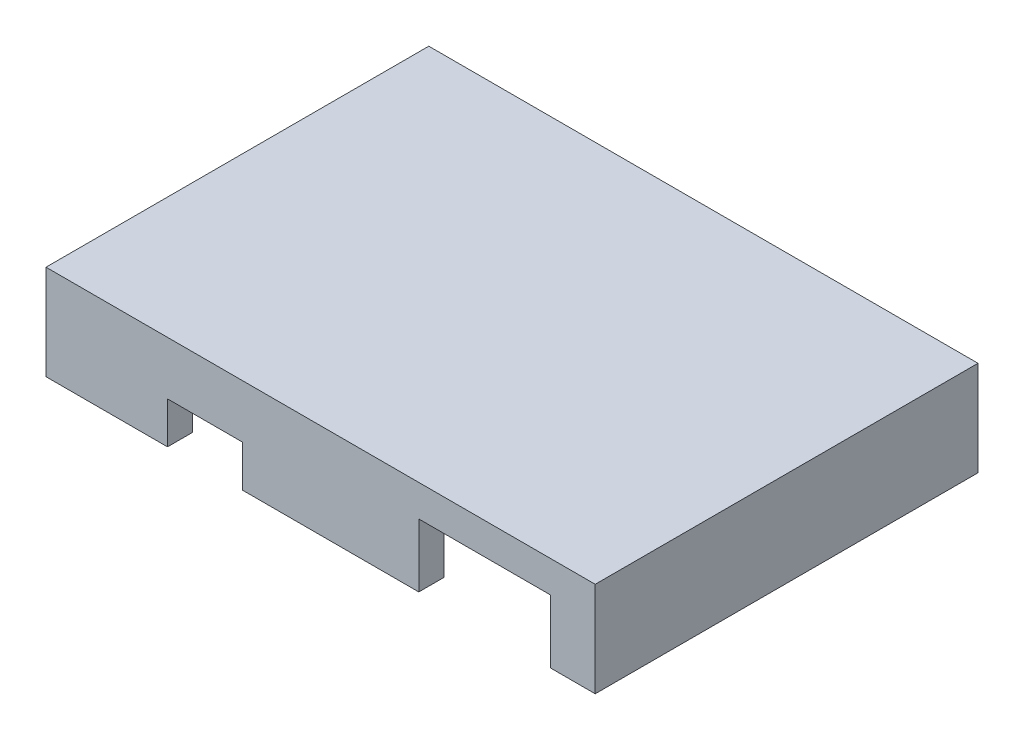
from build123d import *

# Parameters (mm, degrees)
SKETCH1_W           = 33
SKETCH1_H           = 23
SKETCH1_W_2         = 30
SKETCH1_H_2         = 20
BOSS_EXTRUDE1_DEPTH = 5.7
SKETCH2_W           = 30
SKETCH2_H           = 20
BOSS_EXTRUDE2_DEPTH = 1.5
CUT_EXTRUDE1_REACH  = 25
SKETCH3_W           = 7.5
SKETCH3_H           = 3.6
CUT_EXTRUDE2_REACH  = 25
SKETCH4_W           = 7.9
SKETCH4_H           = 7.6
SKETCH4_W_2         = 4.5
SKETCH4_H_2         = 5
CUT_EXTRUDE3_REACH  = 35
SKETCH5_W           = 3.35
SKETCH5_H           = 5
SKETCH6_W           = 2
SKETCH6_H           = 12.5
BOSS_EXTRUDE3_DEPTH = 2.2
SKETCH7_W           = 1.2
SKETCH7_H           = 3.3
SKETCH7_H_2         = 1.2
BOSS_EXTRUDE4_DEPTH = 3.2


with BuildPart() as part:
    # Sketch1 → Boss-Extrude1 (new body)
    with BuildSketch(Plane(origin=(0, 0, 0), x_dir=(1, 0, 0), z_dir=(0, 1, 0))):
        Rectangle(SKETCH1_W, SKETCH1_H)
        Rectangle(SKETCH1_W_2, SKETCH1_H_2, mode=Mode.SUBTRACT)
    extrude(amount=BOSS_EXTRUDE1_DEPTH)

    # Sketch2 → Boss-Extrude2 (add)
    with BuildSketch(Plane(origin=(0, 5.7, 0), x_dir=(1, 0, 0), z_dir=(0, 1, 0))):
        Rectangle(SKETCH2_W, SKETCH2_H)
    extrude(amount=-BOSS_EXTRUDE2_DEPTH)

    # Sketch3 → Cut-Extrude1 (cut, up to next)
    with BuildSketch(Plane(origin=(0, 0, -11.5), x_dir=(-1, 0, 0), z_dir=(0, 0, -1)), mode=Mode.PRIVATE) as cut_extrude1_sk1:
        with Locations((9.75, 0)):
            Rectangle(SKETCH3_W, SKETCH3_H)
    cut_extrude1_tool1 = extrude(cut_extrude1_sk1.sketch, amount=-CUT_EXTRUDE1_REACH, mode=Mode.PRIVATE) & part.part
    add(cut_extrude1_tool1.solids().sort_by_distance((-9.75, 0, -11.5))[0], mode=Mode.SUBTRACT)

    # Sketch4 → Cut-Extrude2 (cut, up to next)
    with BuildSketch(Plane.XY.offset(11.5), mode=Mode.PRIVATE) as cut_extrude2_sk1:
        with Locations((9.85, 0)):
            Rectangle(SKETCH4_W, SKETCH4_H)
    cut_extrude2_tool1 = extrude(cut_extrude2_sk1.sketch, amount=-CUT_EXTRUDE2_REACH, mode=Mode.PRIVATE) & part.part
    add(cut_extrude2_tool1.solids().sort_by_distance((9.85, 0, 11.5))[0], mode=Mode.SUBTRACT)
    # Sketch4 → Cut-Extrude2 (cut, up to next)
    with BuildSketch(Plane.XY.offset(11.5), mode=Mode.PRIVATE) as cut_extrude2_sk2:
        with Locations((-6.95, 0)):
            Rectangle(SKETCH4_W_2, SKETCH4_H_2)
    cut_extrude2_tool2 = extrude(cut_extrude2_sk2.sketch, amount=-CUT_EXTRUDE2_REACH, mode=Mode.PRIVATE) & part.part
    add(cut_extrude2_tool2.solids().sort_by_distance((-6.95, 0, 11.5))[0], mode=Mode.SUBTRACT)

    # Sketch5 → Cut-Extrude3 (cut, up to next)
    with BuildSketch(Plane.ZY.offset(16.5), mode=Mode.PRIVATE) as cut_extrude3_sk1:
        with Locations((5.175, 0)):
            Rectangle(SKETCH5_W, SKETCH5_H)
    cut_extrude3_tool1 = extrude(cut_extrude3_sk1.sketch, amount=-CUT_EXTRUDE3_REACH, mode=Mode.PRIVATE) & part.part
    add(cut_extrude3_tool1.solids().sort_by_distance((-16.5, 0, 5.175))[0], mode=Mode.SUBTRACT)

    # Sketch6 → Boss-Extrude3 (add)
    with BuildSketch(Plane.XZ.offset(-4.2)):
        with Locations((14, -3.75)):
            Rectangle(SKETCH6_W, SKETCH6_H)
    extrude(amount=BOSS_EXTRUDE3_DEPTH)

    # Sketch7 → Boss-Extrude4 (add)
    with BuildSketch(Plane.XZ.offset(-4.2)):
        with Locations((-14.4, -4.95)):
            Rectangle(SKETCH7_W, SKETCH7_H)
        with Locations((-14.4, 9.4)):
            Rectangle(SKETCH7_W, SKETCH7_H_2)
    extrude(amount=BOSS_EXTRUDE4_DEPTH)


solid = part.part
